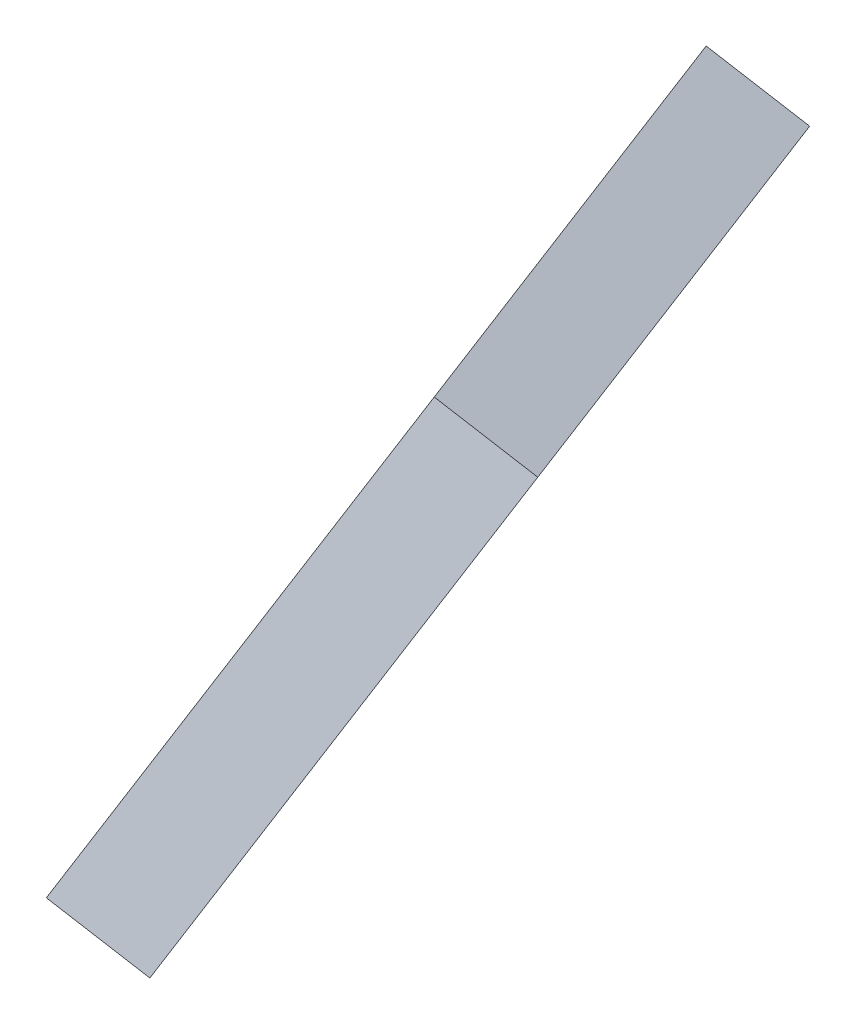
from build123d import *

# Parameters (mm, degrees)
BOSS_EXTRUDE1_DEPTH = 2.8


with BuildPart() as part:
    # Sketch2 → Boss-Extrude1 (new body)
    with BuildSketch(Plane(origin=(-19.796637957, 12.234995121, 7.561642837), x_dir=(-0.262865556, 0.162459848, -0.951056516), z_dir=(0.809016994, -0.5, -0.309016994))):
        Polygon((-40.543437921, 50.167685709), (-37.596697082, 49.604908287), (-38.374436352, 45.532612603), (-41.668992766, 43.015795458), (-43.490178761, 45.399758875), (-51.492059519, 39.286865923), (-60.475384548, 50.668863614), (-52.852283422, 63.003300335), (-38.654450114, 60.058554275), align=None)
    extrude(amount=BOSS_EXTRUDE1_DEPTH)


solid = part.part
